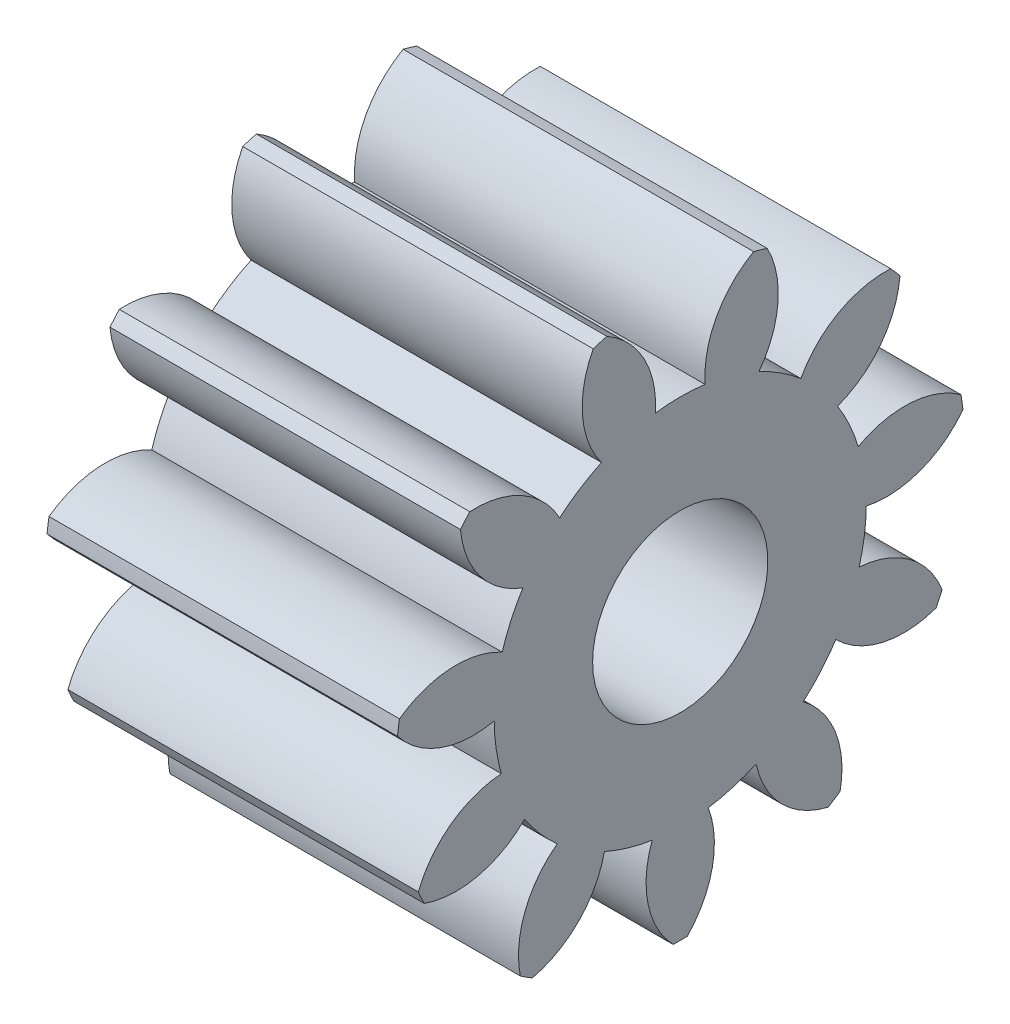
from build123d import *

# Parameters (mm, degrees)
BASPROSKE_W     = 2
BASPROSKE_H     = 1.625
TOOTHCUT_DEPTH  = 4.046514402
TEETHCUTS_COUNT = 11
TEETHCUTS_ANGLE = 327.272727273
BORSKE_R        = 0.5
BORE_DEPTH      = 50.0000508


with BuildPart() as part:
    # BasProSke → Base-Revolve (revolve)
    with BuildSketch(Plane(origin=(0, 0, 0), x_dir=(1, 0, 0), z_dir=(0, 1, 0)), mode=Mode.PRIVATE) as base_revolve_sk:
        with Locations((1, 0.8125)):
            Rectangle(BASPROSKE_W, BASPROSKE_H)
    revolve(base_revolve_sk.sketch.rotate(Axis((-10, 0, 0), (1, 0, 0)), 180), axis=Axis((-10, 0, 0), (1, 0, 0)))

    # TooCutSke → ToothCut (cut, through all)
    with BuildSketch(Plane(origin=(0, 0, 0), x_dir=(0, 0, -1), z_dir=(1, 0, 0))):
        with BuildLine():
            ThreePointArc((0.142039792, 1.051953871), (0, 1.0615), (-0.142039792, 1.051953871))
            ThreePointArc((-0.142039792, 1.051953871), (-0.214419225, 1.367318904), (-0.451594534, 1.587413789))
            ThreePointArc((-0.451594534, 1.587413789), (0, 1.6504), (0.451594534, 1.587413789))
            ThreePointArc((0.451594534, 1.587413789), (0.214419225, 1.367318904), (0.142039792, 1.051953871))
        make_face()
    toothcut = extrude(amount=TOOTHCUT_DEPTH, mode=Mode.SUBTRACT)

    # TeethCuts: ToothCut ×11 about axis
    teethcuts_axis = Axis((-10, 0, 0), (1, 0, 0))
    for i in range(1, TEETHCUTS_COUNT):
        add(toothcut.rotate(teethcuts_axis, i * TEETHCUTS_ANGLE / (TEETHCUTS_COUNT - 1)), mode=Mode.SUBTRACT)

    # BorSke → Bore (cut, symmetric)
    with BuildSketch(Plane(origin=(0, 0, 0), x_dir=(0, 0, -1), z_dir=(1, 0, 0))):
        with Locations(Location((0, 0, 0), (0, 0, 180))):
            Circle(BORSKE_R)
    extrude(amount=BORE_DEPTH, both=True, mode=Mode.SUBTRACT)


solid = part.part
